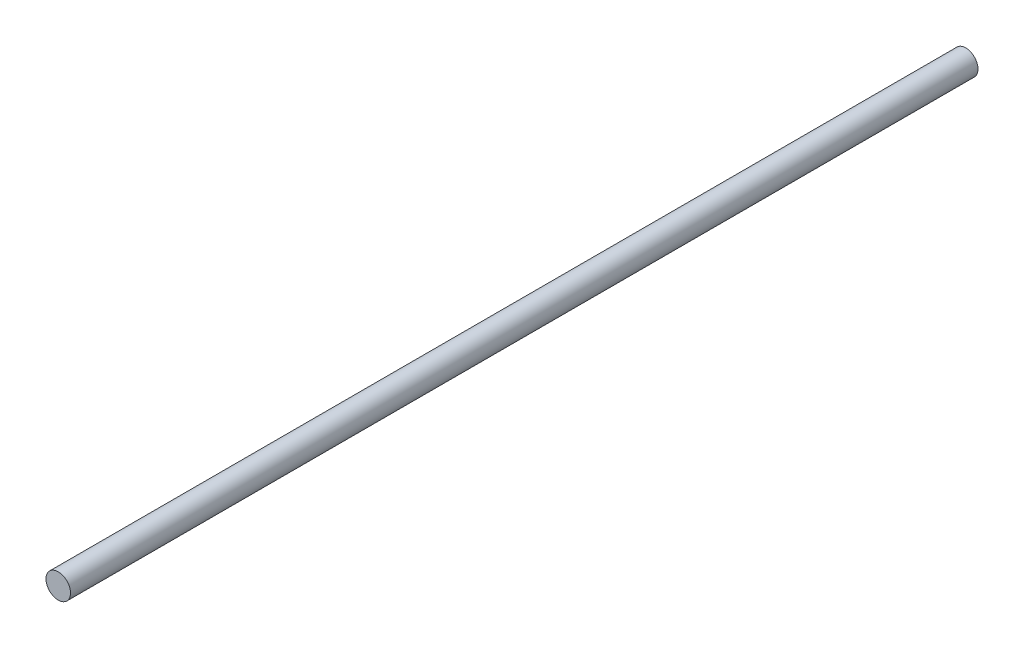
from build123d import *

# Parameters (mm, degrees)
SKETCH2_W = 295.8
SKETCH2_H = 4


with BuildPart() as part:
    # Sketch2 → Revolve1 (revolve)
    with BuildSketch(Plane(origin=(0, 0, 0), x_dir=(0, 0, -1), z_dir=(1, 0, 0))):
        with Locations((130, 2)):
            Rectangle(SKETCH2_W, SKETCH2_H)
    revolve(axis=Axis((0, 0, 17.9), (0, 0, -1)))


solid = part.part
